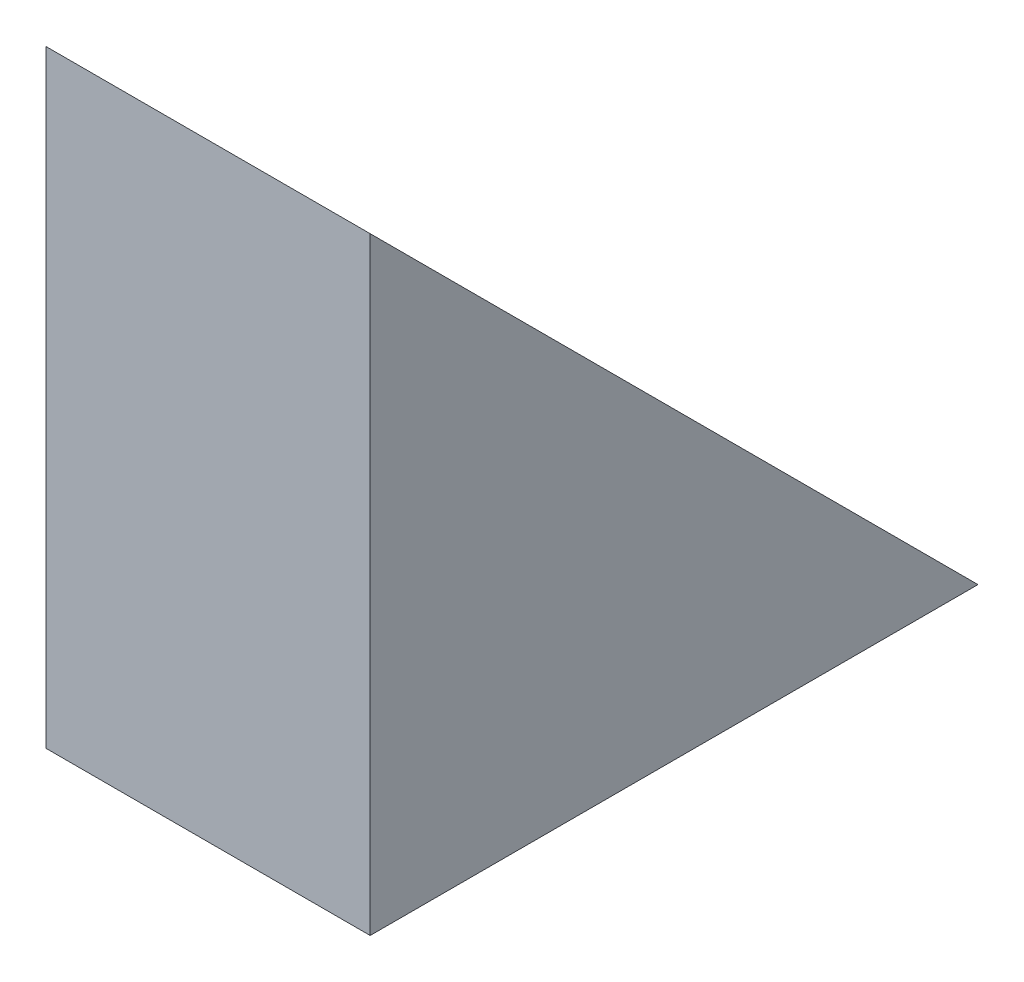
from build123d import *

# Parameters (mm, degrees)
Y_KSEKLIK_EKSTR_ZYON1_DEPTH = 80


with BuildPart() as part:
    # Çizim1 → Yükseklik-Ekstrüzyon1 (new body)
    with BuildSketch(Plane(origin=(0, 0, 0), x_dir=(0, 0, -1), z_dir=(1, 0, 0))):
        Polygon((0, 150), (0, 0), (150, 0), align=None)
    extrude(amount=-Y_KSEKLIK_EKSTR_ZYON1_DEPTH)


solid = part.part
